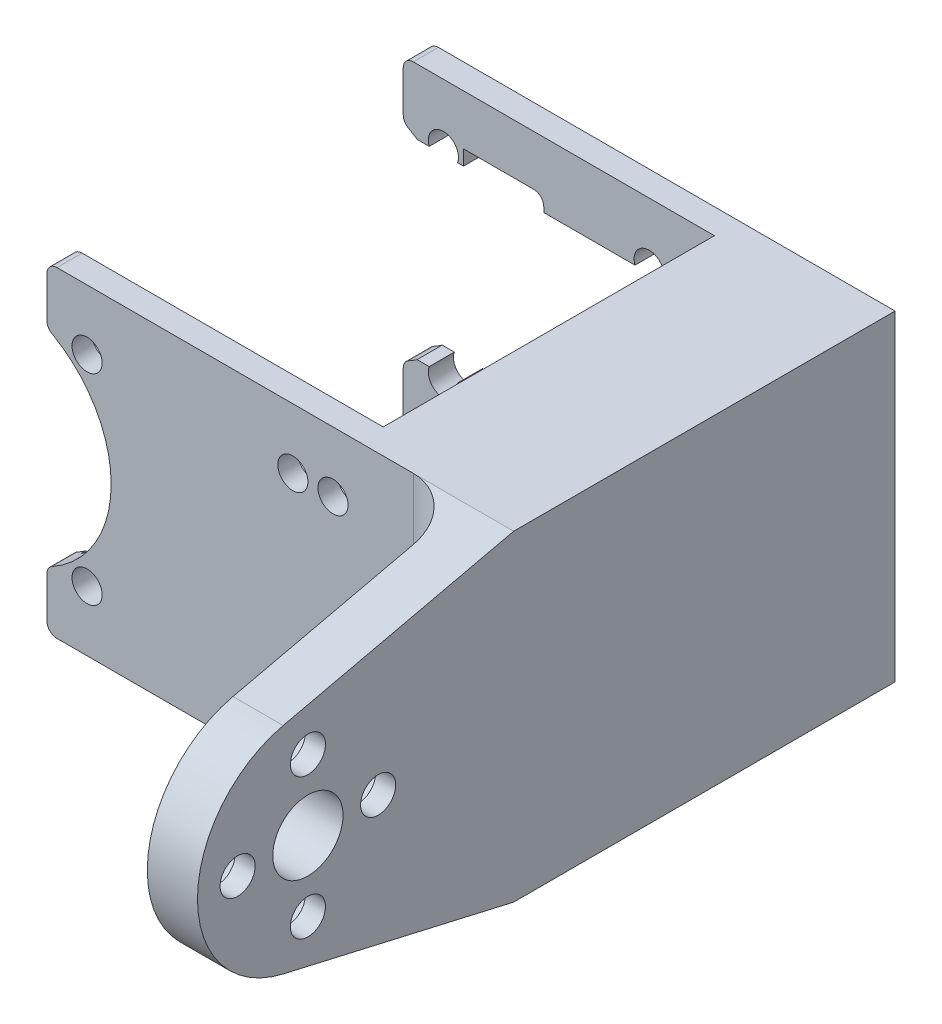
from build123d import *

# Parameters (mm, degrees)
SKETCH_1_W               = 33.5
SKETCH_1_H               = 32
SKETCH_1_R               = 1.5
EXTRUDE_1_DEPTH          = 38
SKETCH_2_W               = 33
SKETCH_2_H               = 32
CUT_EXTRUDE_1_DEPTH      = 31
SKETCH_4_R               = 11.5
CUT_EXTRUDE_2_DEPTH      = 39
SKETCH_5_W               = 31
SKETCH_5_H               = 19
CUT_EXTRUDE_3_DEPTH      = 33.5
CUT_EXTRUDE_3_DEPTH_BACK = 11.5
SKETCH_8_W               = 38
SKETCH_8_H               = 32
EXTRUDE_3_DEPTH          = 4
EXTRUDE_4_DEPTH          = 9
SKETCH_11_W              = 8
SKETCH_11_H              = 1.5
CUT_EXTRUDE_4_DEPTH      = 10
FILLET_3_R               = 1
SKETCH_12_R              = 1.75
CUT_EXTRUDE_5_DEPTH      = 47.5
SKETCH_13_R              = 3.5
CUT_EXTRUDE_6_DEPTH      = 10
SKETCH_15_W              = 31.5
SKETCH_15_H              = 32
CUT_EXTRUDE_7_DEPTH      = 4
SKETCH_16_R              = 3
CUT_EXTRUDE_8_DEPTH      = 3
FILLET_4_R               = 5


with BuildPart() as part:
    # Эскиз1 → Бобышка-Вытянуть1 (new body)
    with BuildSketch(Plane.XY):
        with Locations((2.5, 0)):
            Rectangle(SKETCH_1_W, SKETCH_1_H)
        with Locations((10.25, -10)):
            Circle(SKETCH_1_R, mode=Mode.SUBTRACT)
        with Locations((-10.25, -10)):
            Circle(SKETCH_1_R, mode=Mode.SUBTRACT)
        with Locations((14.25, -10)):
            Circle(SKETCH_1_R, mode=Mode.SUBTRACT)
        with Locations((14.25, 10)):
            Circle(SKETCH_1_R, mode=Mode.SUBTRACT)
        with Locations((10.25, 10)):
            Circle(SKETCH_1_R, mode=Mode.SUBTRACT)
        with Locations((-10.25, 10)):
            Circle(SKETCH_1_R, mode=Mode.SUBTRACT)
    extrude(amount=-EXTRUDE_1_DEPTH)

    # Эскиз2 → Вырез-Вытянуть1 (cut)
    with BuildSketch(Plane.ZY.offset(14.25)):
        with Locations((-19, 0)):
            Rectangle(SKETCH_2_W, SKETCH_2_H)
    extrude(amount=-CUT_EXTRUDE_1_DEPTH, mode=Mode.SUBTRACT)

    # Эскиз4 → Вырез-Вытянуть2 (cut, through all)
    with BuildSketch(Plane(origin=(0, 0, -38), x_dir=(-1, 0, 0), z_dir=(0, 0, -1))):
        with Locations((19.35, 0)):
            Circle(SKETCH_4_R)
    extrude(amount=-CUT_EXTRUDE_2_DEPTH, mode=Mode.SUBTRACT)

    # Эскиз5 → Вырез-Вытянуть3 (cut, two sides)
    with BuildSketch(Plane.XY.offset(-35.5)) as cut_extrude_3_sk:
        with Locations((1.25, 0)):
            Rectangle(SKETCH_5_W, SKETCH_5_H)
    extrude(amount=CUT_EXTRUDE_3_DEPTH, mode=Mode.SUBTRACT)
    extrude(cut_extrude_3_sk.sketch, amount=-CUT_EXTRUDE_3_DEPTH_BACK, mode=Mode.SUBTRACT)

    # Эскиз8 → Бобышка-Вытянуть3 (add)
    with BuildSketch(Plane(origin=(19.25, 0, 0), x_dir=(0, 0, -1), z_dir=(1, 0, 0))):
        with Locations((19, 0)):
            Rectangle(SKETCH_8_W, SKETCH_8_H)
    extrude(amount=EXTRUDE_3_DEPTH)

    # Эскиз10 → Бобышка-Вытянуть4 (add)
    with BuildSketch(Plane(origin=(23.25, 0, 0), x_dir=(0, 0, -1), z_dir=(1, 0, 0))):
        with BuildLine():
            Line((38, 16), (0, 16))
            Line((0, 16), (-22.964648913, 10.720331419))
            ThreePointArc((-22.964648913, 10.720331419), (-31.5, 0), (-22.964648913, -10.720331419))
            Line((-22.964648913, -10.720331419), (0, -16))
            Line((0, -16), (38, -16))
            Line((38, -16), (38, 16))
        make_face()
    extrude(amount=EXTRUDE_4_DEPTH)

    # Эскиз11 → Вырез-Вытянуть4 (cut)
    with BuildSketch(Plane(origin=(0, 0, -38), x_dir=(-1, 0, 0), z_dir=(0, 0, -1))):
        with Locations((4.25, 10.25)):
            Rectangle(SKETCH_11_W, SKETCH_11_H)
        with Locations((4.25, -10.25)):
            Rectangle(SKETCH_11_W, SKETCH_11_H)
    extrude(amount=-CUT_EXTRUDE_4_DEPTH, mode=Mode.SUBTRACT)

    # Скругление3
    fillet_3_edges = [part.edges().sort_by_distance(p)[0] for p in [
        (-14.25, -16, -36.75),
        (-14.25, 16, -36.75),
        (-0.25, 11, -36.75),
        (-8.25, -11, -36.75),
        (-0.25, -11, -36.75),
        (-14.25, 16, -1.25),
        (-14.25, -16, -1.25),
        (-14.25, 10.307278981, -1.25),
        (-14.25, -10.307278981, -1.25),
        (-14.25, 10.307278981, -36.75),
        (-14.25, -10.307278981, -36.75),
    ]]
    fillet(fillet_3_edges, radius=FILLET_3_R)

    # Эскиз12 → Вырез-Вытянуть5 (cut, through all)
    with BuildSketch(Plane(origin=(32.25, 0, 0), x_dir=(0, 0, -1), z_dir=(1, 0, 0))):
        with Locations((-27.5, 0)):
            Circle(SKETCH_12_R)
        with Locations((-20.5, 7)):
            Circle(SKETCH_12_R)
        with Locations((-13.5, 0)):
            Circle(SKETCH_12_R)
        with Locations((-20.5, -7)):
            Circle(SKETCH_12_R)
    extrude(amount=-CUT_EXTRUDE_5_DEPTH, mode=Mode.SUBTRACT)

    # Эскиз13 → Вырез-Вытянуть6 (cut)
    with BuildSketch(Plane.ZY.offset(-23.25)):
        with Locations((20.5, 0)):
            Circle(SKETCH_13_R)
    extrude(amount=-CUT_EXTRUDE_6_DEPTH, mode=Mode.SUBTRACT)

    # Эскиз15 → Вырез-Вытянуть7 (cut)
    with BuildSketch(Plane.ZY.offset(-23.25)):
        with Locations((15.75, 0)):
            Rectangle(SKETCH_15_W, SKETCH_15_H)
    extrude(amount=-CUT_EXTRUDE_7_DEPTH, mode=Mode.SUBTRACT)

    # Эскиз16 → Вырез-Вытянуть8 (cut)
    with BuildSketch(Plane.ZY.offset(-27.25)):
        with Locations((20.5, 7)):
            Circle(SKETCH_16_R)
        with Locations((27.5, 0)):
            Circle(SKETCH_16_R)
        with Locations((20.5, -7)):
            Circle(SKETCH_16_R)
        with Locations((13.5, 0)):
            Circle(SKETCH_16_R)
    extrude(amount=-CUT_EXTRUDE_8_DEPTH, mode=Mode.SUBTRACT)

    # Скругление4
    fillet_4_edges = [part.edges().sort_by_distance(p)[0] for p in [
        (27.25, 0, 0),
    ]]
    fillet(fillet_4_edges, radius=FILLET_4_R)


solid = part.part
